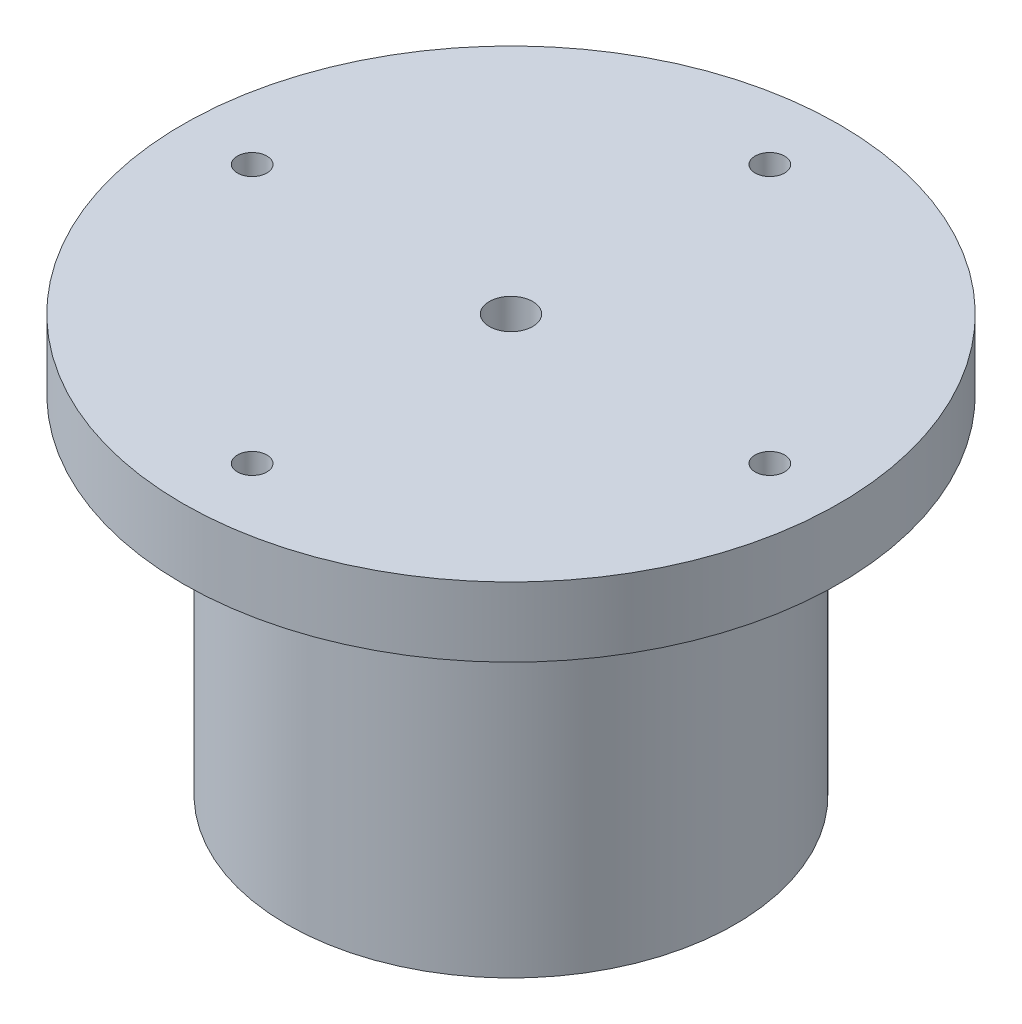
from build123d import *

# Parameters (mm, degrees)
SKETCH1_R           = 25.825
SKETCH1_R_2         = 17.825
BOSS_EXTRUDE1_DEPTH = 40
SKETCH2_R           = 37.825
BOSS_EXTRUDE2_DEPTH = 8
SKETCH4_R           = 1.7
CUT_EXTRUDE2_DEPTH  = 67.794170779
SKETCH5_R           = 2.85
CUT_EXTRUDE3_DEPTH  = 4
FILLET1_R           = 2
SKETCH6_R           = 2.5
CUT_EXTRUDE4_DEPTH  = 67.794170779


with BuildPart() as part:
    # Sketch1 → Boss-Extrude1 (new body)
    with BuildSketch(Plane(origin=(0, 0, 0), x_dir=(1, 0, 0), z_dir=(0, 1, 0))):
        Circle(SKETCH1_R)
        Circle(SKETCH1_R_2, mode=Mode.SUBTRACT)
    extrude(amount=BOSS_EXTRUDE1_DEPTH)

    # Sketch2 → Boss-Extrude2 (add)
    with BuildSketch(Plane(origin=(0, 40, 0), x_dir=(1, 0, 0), z_dir=(0, 1, 0))):
        Circle(SKETCH2_R)
    extrude(amount=BOSS_EXTRUDE2_DEPTH)

    # Sketch4 → Cut-Extrude2 (cut, through all)
    with BuildSketch(Plane.XZ.offset(-40)):
        with Locations((0, 29.825)):
            Circle(SKETCH4_R)
        with Locations((29.825, 0)):
            Circle(SKETCH4_R)
        with Locations((0, -29.825)):
            Circle(SKETCH4_R)
        with Locations((-29.825, 0)):
            Circle(SKETCH4_R)
    extrude(amount=-CUT_EXTRUDE2_DEPTH, mode=Mode.SUBTRACT)

    # Sketch5 → Cut-Extrude3 (cut)
    with BuildSketch(Plane.XZ.offset(-40)):
        with Locations((0, 29.825)):
            Circle(SKETCH5_R)
        with Locations((29.825, 0)):
            Circle(SKETCH5_R)
        with Locations((0, -29.825)):
            Circle(SKETCH5_R)
        with Locations((-29.825, 0)):
            Circle(SKETCH5_R)
    extrude(amount=-CUT_EXTRUDE3_DEPTH, mode=Mode.SUBTRACT)

    # Fillet1
    fillet1_edges = [part.edges().sort_by_distance(p)[0] for p in [
        (-17.825, 0, 0),
    ]]
    fillet(fillet1_edges, radius=FILLET1_R)

    # Sketch6 → Cut-Extrude4 (cut, through all)
    with BuildSketch(Plane.XZ.offset(-40)):
        Circle(SKETCH6_R)
    extrude(amount=-CUT_EXTRUDE4_DEPTH, mode=Mode.SUBTRACT)


solid = part.part
